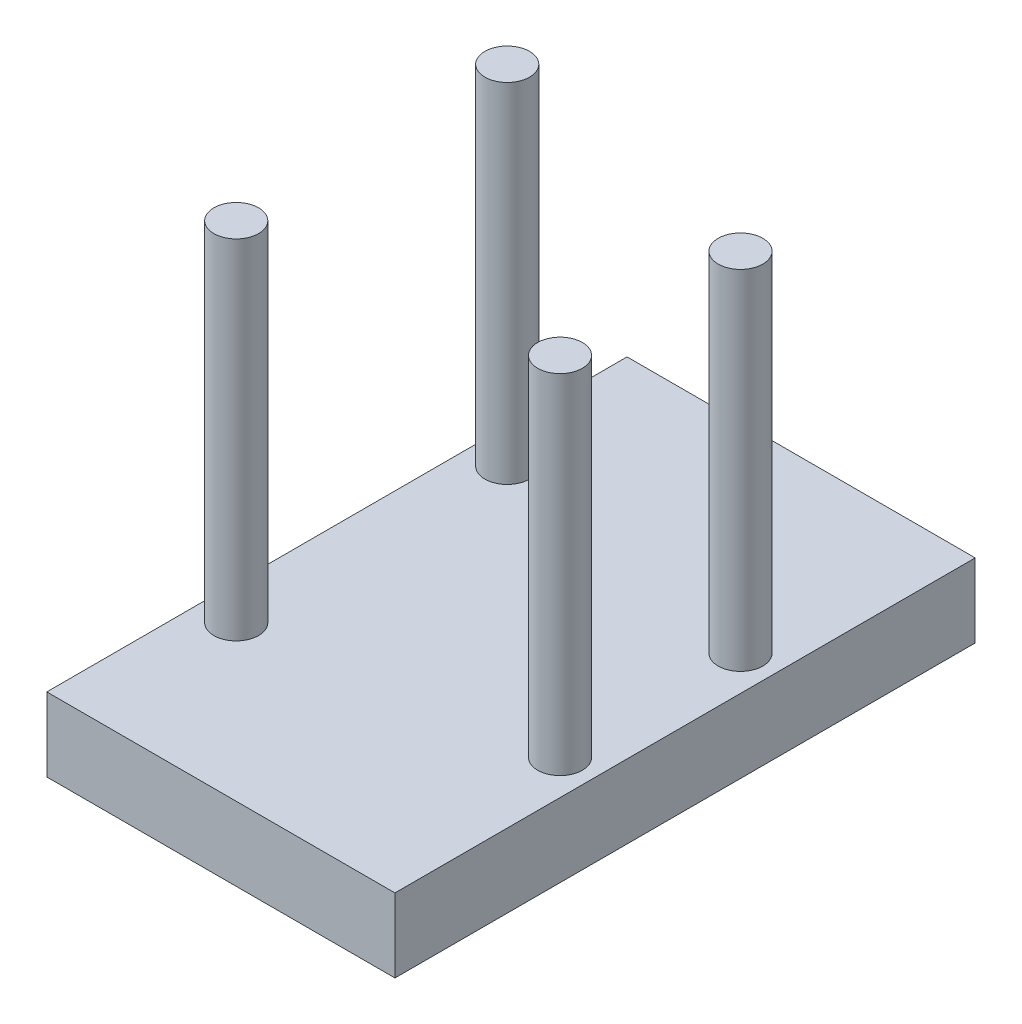
from build123d import *

# Parameters (mm, degrees)
SKETCH1_W           = 60
SKETCH1_H           = 100
BOSS_EXTRUDE1_DEPTH = 12.7
SKETCH8_R           = 3.85
BOSS_EXTRUDE2_DEPTH = 60


with BuildPart() as part:
    # Sketch1 → Boss-Extrude1 (new body)
    with BuildSketch(Plane(origin=(0, 0, 0), x_dir=(1, 0, 0), z_dir=(0, 1, 0))):
        Rectangle(SKETCH1_W, SKETCH1_H)
    extrude(amount=BOSS_EXTRUDE1_DEPTH)

    # Sketch8 → Boss-Extrude2 (add)
    with BuildSketch(Plane(origin=(0, 12.7, 0), x_dir=(1, 0, 0), z_dir=(0, 1, 0))):
        with Locations((-24, 23.35)):
            Circle(SKETCH8_R)
        with Locations((-24, -23.35)):
            Circle(SKETCH8_R)
        with Locations((24, -15.55)):
            Circle(SKETCH8_R)
        with Locations((24, 15.55)):
            Circle(SKETCH8_R)
    extrude(amount=BOSS_EXTRUDE2_DEPTH)


solid = part.part
